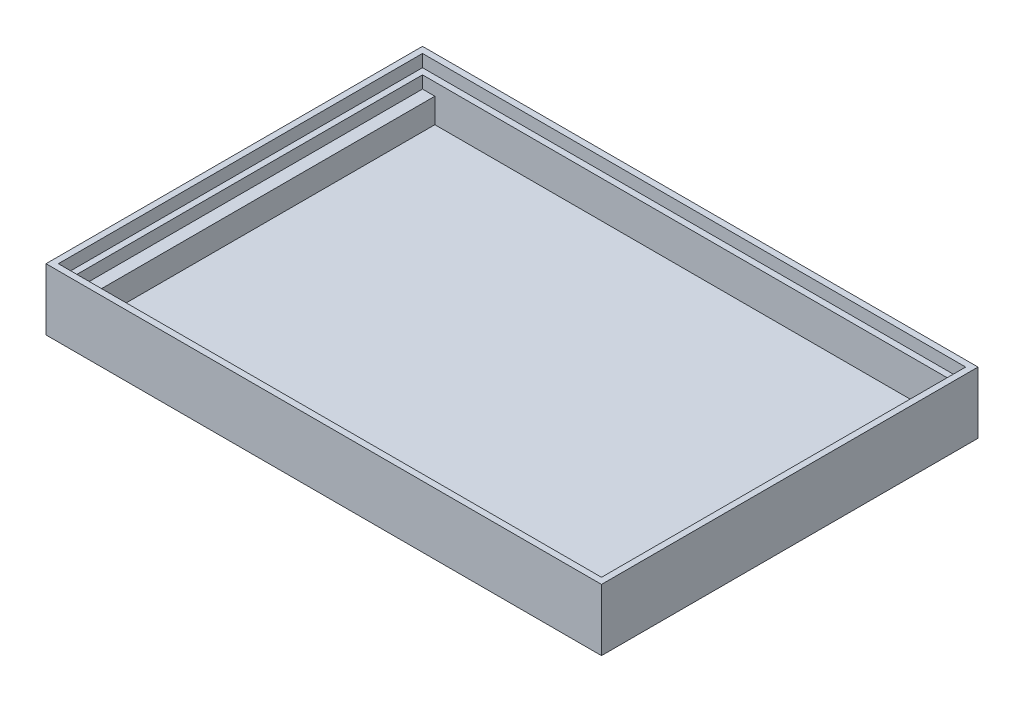
from build123d import *

# Parameters (mm, degrees)
SKETCH1_W           = 90
SKETCH1_H           = 61
BOSS_EXTRUDE1_DEPTH = 2
SKETCH2_W           = 90
SKETCH2_H           = 61
SKETCH2_W_2         = 86
SKETCH2_H_2         = 57
BOSS_EXTRUDE2_DEPTH = 8
SKETCH3_W           = 26
SKETCH3_H           = 7
CUT_EXTRUDE1_DEPTH  = 2
SKETCH4_W           = 2
SKETCH4_H           = 57
BOSS_EXTRUDE3_DEPTH = 4
SKETCH5_W           = 88
SKETCH5_H           = 59
SKETCH5_W_2         = 86
SKETCH5_H_2         = 57
CUT_EXTRUDE2_DEPTH  = 2


with BuildPart() as part:
    # Sketch1 → Boss-Extrude1 (new body)
    with BuildSketch(Plane(origin=(0, 0, 0), x_dir=(1, 0, 0), z_dir=(0, 1, 0))):
        with Locations((45, 30.5)):
            Rectangle(SKETCH1_W, SKETCH1_H)
    extrude(amount=BOSS_EXTRUDE1_DEPTH)

    # Sketch2 → Boss-Extrude2 (add)
    with BuildSketch(Plane(origin=(0, 2, 0), x_dir=(1, 0, 0), z_dir=(0, 1, 0))):
        with Locations((45, 30.5)):
            Rectangle(SKETCH2_W, SKETCH2_H)
        with Locations((45, 30.5)):
            Rectangle(SKETCH2_W_2, SKETCH2_H_2, mode=Mode.SUBTRACT)
    extrude(amount=BOSS_EXTRUDE2_DEPTH)

    # Sketch3 → Cut-Extrude1 (cut)
    with BuildSketch(Plane(origin=(0, 2, 0), x_dir=(1, 0, 0), z_dir=(0, 1, 0))):
        with Locations((70, 5.5)):
            Rectangle(SKETCH3_W, SKETCH3_H)
    extrude(amount=-CUT_EXTRUDE1_DEPTH, mode=Mode.SUBTRACT)

    # Sketch4 → Boss-Extrude3 (add)
    with BuildSketch(Plane(origin=(0, 2, 0), x_dir=(1, 0, 0), z_dir=(0, 1, 0))):
        with Locations((3, 30.5)):
            Rectangle(SKETCH4_W, SKETCH4_H)
        with Locations((87, 30.5)):
            Rectangle(SKETCH4_W, SKETCH4_H)
    extrude(amount=BOSS_EXTRUDE3_DEPTH)

    # Sketch5 → Cut-Extrude2 (cut)
    with BuildSketch(Plane(origin=(0, 10, 0), x_dir=(1, 0, 0), z_dir=(0, 1, 0))):
        with Locations((45, 30.5)):
            Rectangle(SKETCH5_W, SKETCH5_H)
        with Locations((45, 30.5)):
            Rectangle(SKETCH5_W_2, SKETCH5_H_2, mode=Mode.SUBTRACT)
    extrude(amount=-CUT_EXTRUDE2_DEPTH, mode=Mode.SUBTRACT)


solid = part.part
